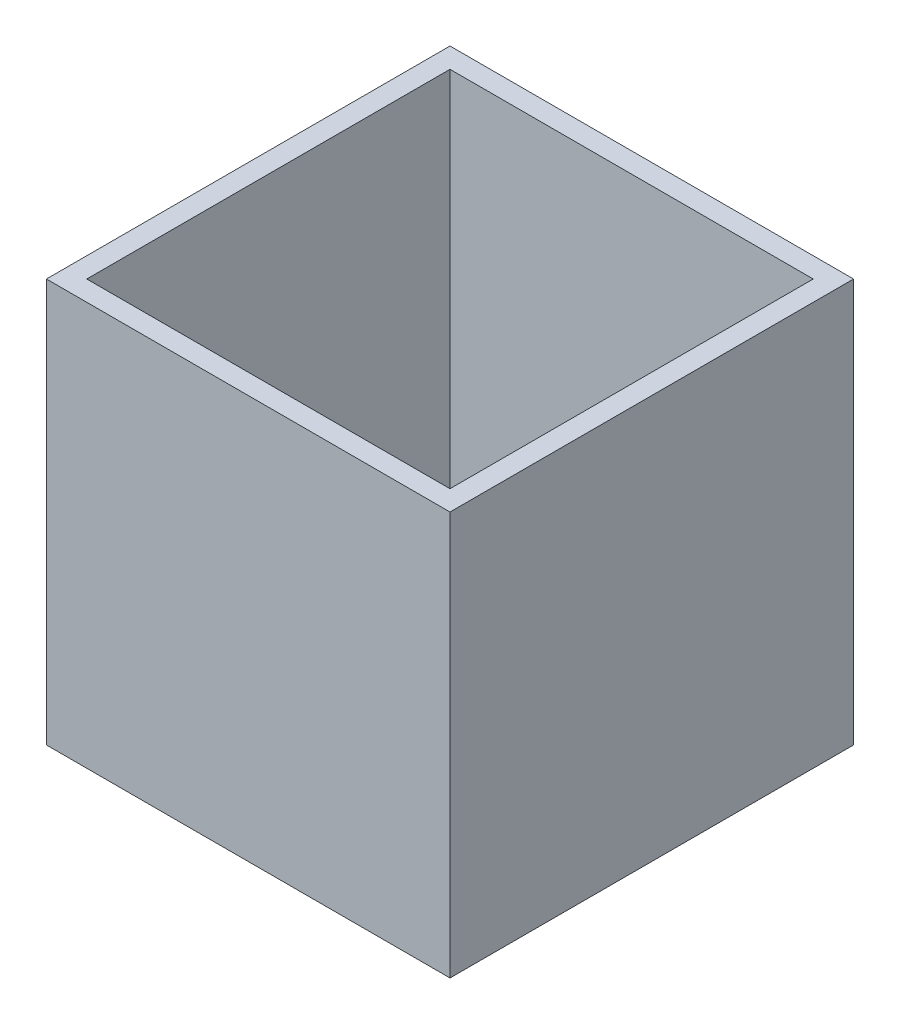
from build123d import *

# Parameters (mm, degrees)
SKETCH1_W           = 40
SKETCH1_H           = 40
SKETCH1_W_2         = 36
SKETCH1_H_2         = 36
EXTRUDE_THIN1_DEPTH = 40


with BuildPart() as part:
    # Sketch1 → Extrude-Thin1 (new body)
    with BuildSketch(Plane(origin=(0, 0, 0), x_dir=(1, 0, 0), z_dir=(0, 1, 0))):
        Rectangle(SKETCH1_W, SKETCH1_H)
        Rectangle(SKETCH1_W_2, SKETCH1_H_2, mode=Mode.SUBTRACT)
    extrude(amount=EXTRUDE_THIN1_DEPTH)


solid = part.part
